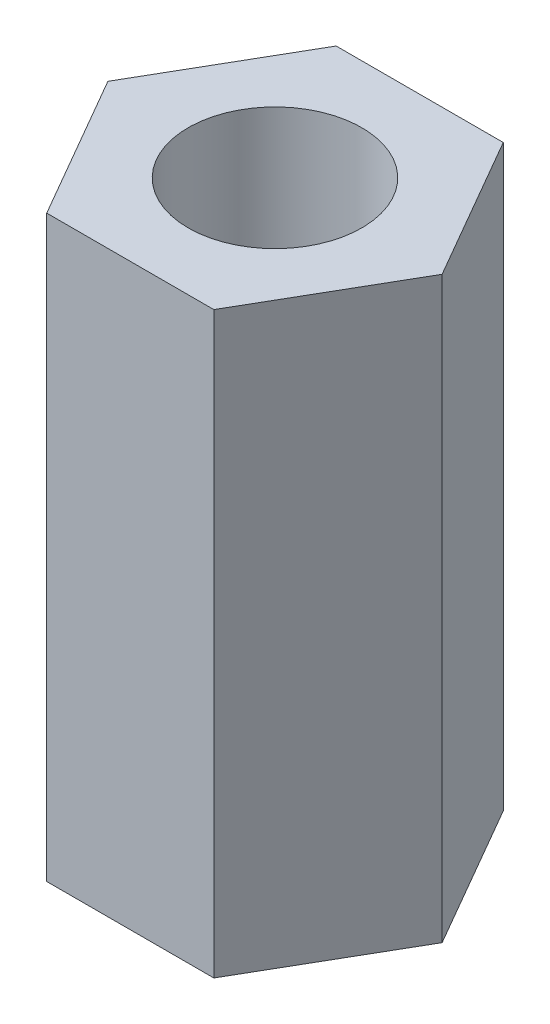
from build123d import *

# Parameters (mm, degrees)
CROQUIS1_R              = 1.5
SALIENTE_EXTRUIR1_DEPTH = 5


with BuildPart() as part:
    # Croquis1 → Saliente-Extruir1 (new body, symmetric)
    with BuildSketch(Plane(origin=(0, 0, 0), x_dir=(1, 0, 0), z_dir=(0, 1, 0))):
        Polygon((1.443375673, -2.5), (2.886751346, 0), (1.443375673, 2.5), (-1.443375673, 2.5), (-2.886751346, 0), (-1.443375673, -2.5), align=None)
        Circle(CROQUIS1_R, mode=Mode.SUBTRACT)
    extrude(amount=SALIENTE_EXTRUIR1_DEPTH, both=True)


solid = part.part
